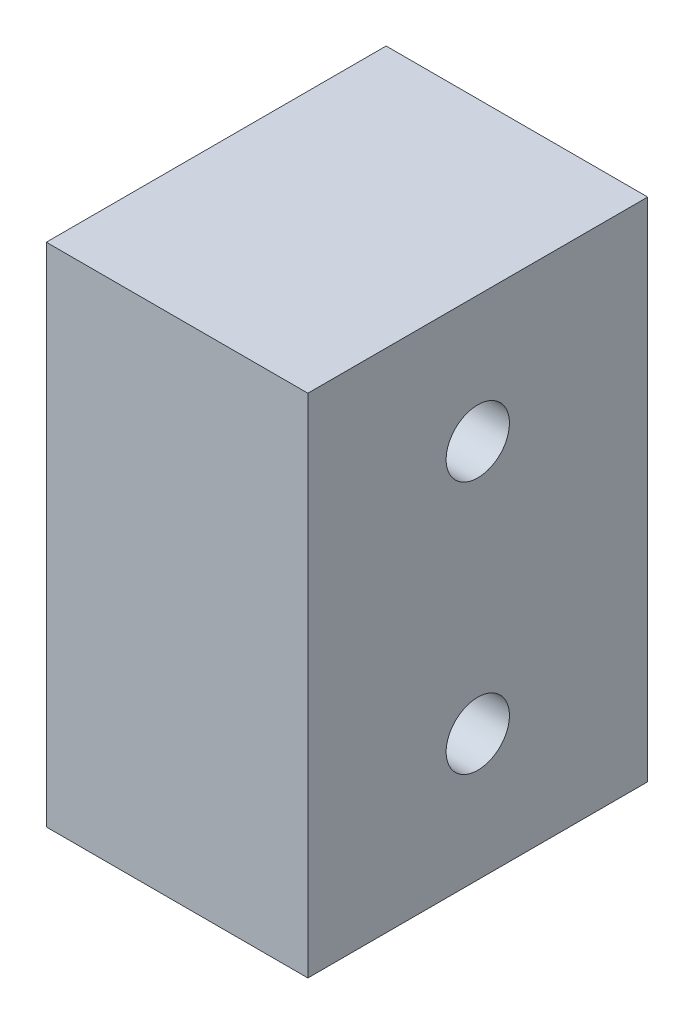
from build123d import *

# Parameters (mm, degrees)
SKETCH1_W           = 20
SKETCH1_H           = 13.42
BOSS_EXTRUDE1_DEPTH = 10.33
SKETCH2_R           = 1.25
CUT_EXTRUDE1_DEPTH  = 10.33


with BuildPart() as part:
    # Sketch1 → Boss-Extrude1 (new body)
    with BuildSketch(Plane.YZ):
        Rectangle(SKETCH1_W, SKETCH1_H)
    extrude(amount=BOSS_EXTRUDE1_DEPTH)

    # Sketch2 → Cut-Extrude1 (cut)
    with BuildSketch(Plane(origin=(10.33, 0, 0), x_dir=(0, 0, -1), z_dir=(1, 0, 0))):
        with Locations((0, 5)):
            Circle(SKETCH2_R)
        with Locations((0, -5)):
            Circle(SKETCH2_R)
    extrude(amount=-CUT_EXTRUDE1_DEPTH, mode=Mode.SUBTRACT)


solid = part.part
